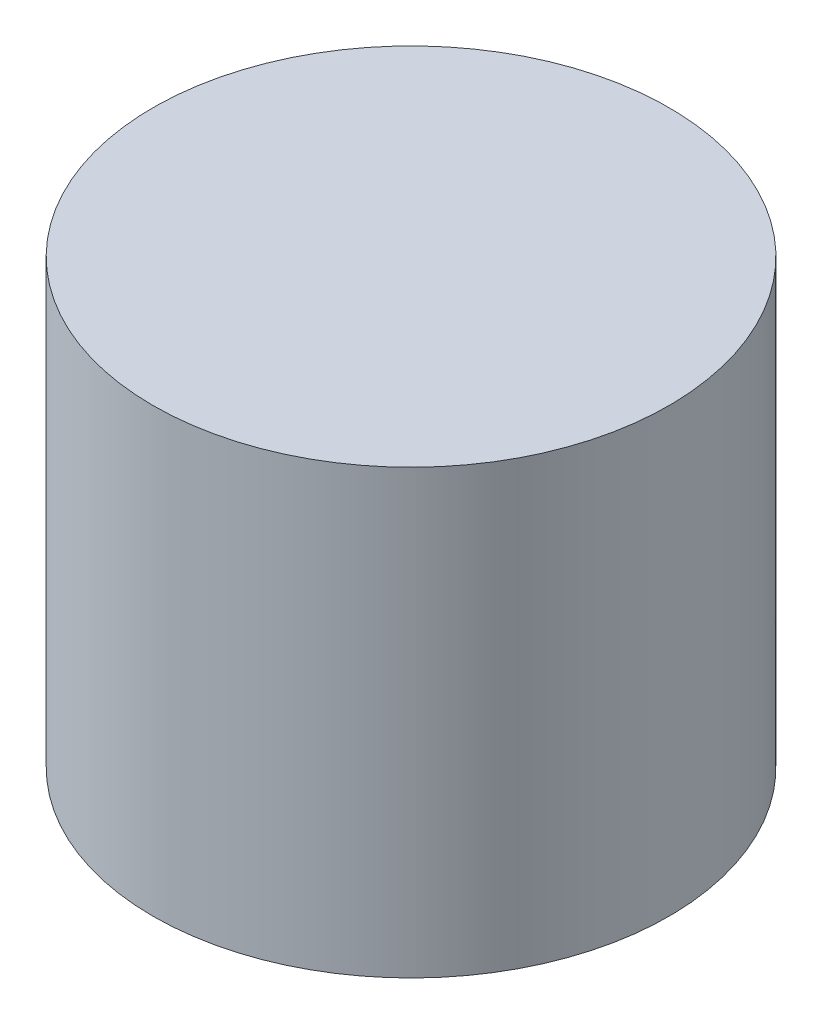
from build123d import *

# Parameters (mm, degrees)
SKETCH1_R           = 3.15
BOSS_EXTRUDE1_DEPTH = 5.4


with BuildPart() as part:
    # Sketch1 → Boss-Extrude1 (new body)
    with BuildSketch(Plane(origin=(0, 0, 0), x_dir=(1, 0, 0), z_dir=(0, 1, 0))):
        with Locations((0, -3.009099384)):
            Circle(SKETCH1_R)
    extrude(amount=BOSS_EXTRUDE1_DEPTH)


solid = part.part
